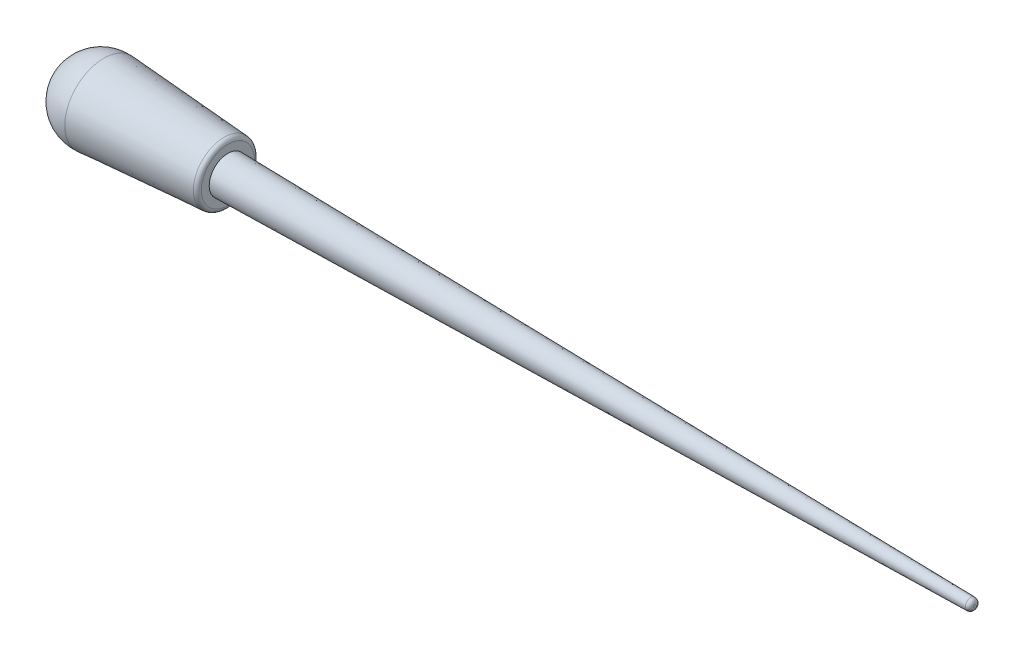
from build123d import *

# Parameters (mm, degrees)
FILLET1_R           = 6.35
SKETCH11_R          = 28.575
BOSS_EXTRUDE2_DEPTH = 1143
FILLET2_R           = 6.35
SCALE1_SCALE        = 0.5
SCALE2_SCALE        = 0.25


with BuildPart() as part:
    # Sketch7 → Revolve4 (revolve)
    with BuildSketch(Plane(origin=(0, 0, 0), x_dir=(1, 0, 0), z_dir=(0, 1, 0))):
        with BuildLine():
            Line((-190.055393274, 59.537811837), (0, 46.530218381))
            Line((0, 46.530218381), (0, 0))
            Line((0, 0), (-253.807316321, 0))
            ThreePointArc((-253.807316321, 0), (-234.86216044, 43.61495939), (-190.055393274, 59.537811837))
        make_face()
    revolve(axis=Axis((-253.807316321, 0, 0), (1, 0, 0)))

    # Fillet1
    fillet1_edges = [part.edges().sort_by_distance(p)[0] for p in [
        (0, 0, 46.530218381),
    ]]
    fillet(fillet1_edges, radius=FILLET1_R)

    # Sketch11 → Boss-Extrude2 (add)
    with BuildSketch(Plane(origin=(0, 0, 0), x_dir=(0, 0, -1), z_dir=(1, 0, 0))):
        Circle(SKETCH11_R)
    extrude(amount=BOSS_EXTRUDE2_DEPTH)

    # Sketch12 → Cut-Revolve1 (revolve, cut)
    with BuildSketch(Plane.XY):
        Polygon((0, 28.575), (1267.855525629, 6.186465308), (456.317793315, 229.960952638), align=None)
    revolve(axis=Axis((0, 0, 0), (1, 0, 0)), mode=Mode.SUBTRACT)

    # Fillet2
    fillet2_edges = [part.edges().sort_by_distance(p)[0] for p in [
        (1143, -8.391237232, 0),
    ]]
    fillet(fillet2_edges, radius=FILLET2_R)


with BuildPart() as part_1:
    # Scale1: scaled about (67.124128352, 0, 0)
    add(part.part.scale(SCALE1_SCALE).moved(Location((33.562064176, 0, 0))))


with BuildPart() as part_2:
    # Scale2: scaled about (67.124128352, 0, 0)
    add(part_1.part.scale(SCALE2_SCALE).moved(Location((50.343096264, 0, 0))))


solid = part_2.part
